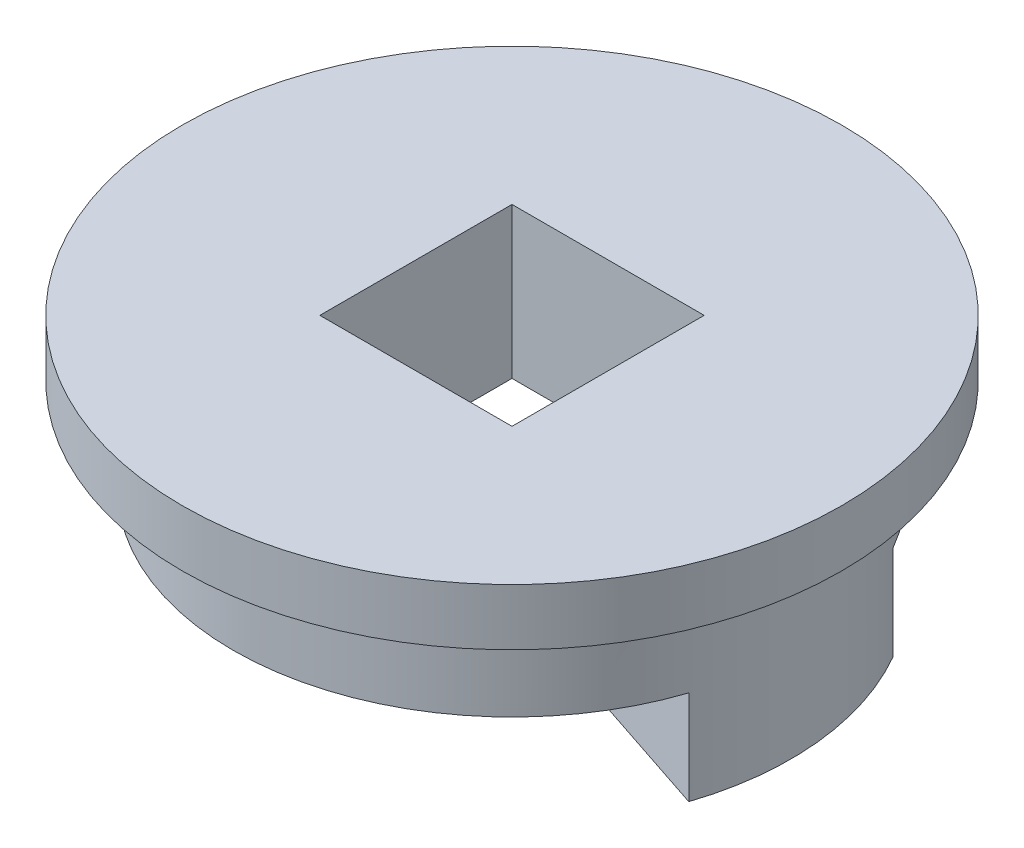
from build123d import *

# Parameters (mm, degrees)
SKETCH_1_R          = 14.8
EXTRUDE_1_DEPTH     = 5
SKETCH_2_R          = 17.5
EXTRUDE_2_DEPTH     = 3
SKETCH_3_W          = 10.2
SKETCH_3_H          = 10.2
CUT_EXTRUDE_1_DEPTH = 9
EXTRUDE_3_DEPTH     = 5


with BuildPart() as part:
    # Эскиз1 → Бобышка-Вытянуть1 (new body)
    with BuildSketch(Plane(origin=(0, 0, 0), x_dir=(1, 0, 0), z_dir=(0, 1, 0))):
        with Locations(Location((0, 0, 0), (0, 0, 270))):  # turned: the seam where the file's is
            Circle(SKETCH_1_R)
    extrude(amount=EXTRUDE_1_DEPTH)

    # Эскиз2 → Бобышка-Вытянуть2 (add)
    with BuildSketch(Plane(origin=(0, 5, 0), x_dir=(1, 0, 0), z_dir=(0, 1, 0))):
        with Locations(Location((0, 0, 0), (0, 0, 270))):  # turned: the seam where the file's is
            Circle(SKETCH_2_R)
    extrude(amount=EXTRUDE_2_DEPTH)

    # Эскиз3 → Вырез-Вытянуть1 (cut, through all)
    with BuildSketch(Plane(origin=(0, 8, 0), x_dir=(1, 0, 0), z_dir=(0, 1, 0))):
        Rectangle(SKETCH_3_W, SKETCH_3_H)
    extrude(amount=-CUT_EXTRUDE_1_DEPTH, mode=Mode.SUBTRACT)

    # Эскиз4 → Бобышка-Вытянуть3 (add)
    with BuildSketch(Plane.XZ):
        with BuildLine():
            Line((14.046133482, 4.663275051), (5.1, 1.693185017))
            Line((5.1, 1.693185017), (5.1, -2.944486373))
            Line((5.1, -2.944486373), (12.817175976, -7.4))
            ThreePointArc((12.817175976, -7.4), (14.723790273, -1.5), (14.046133482, 4.663275051))
        make_face()
    extrude(amount=EXTRUDE_3_DEPTH)


solid = part.part
